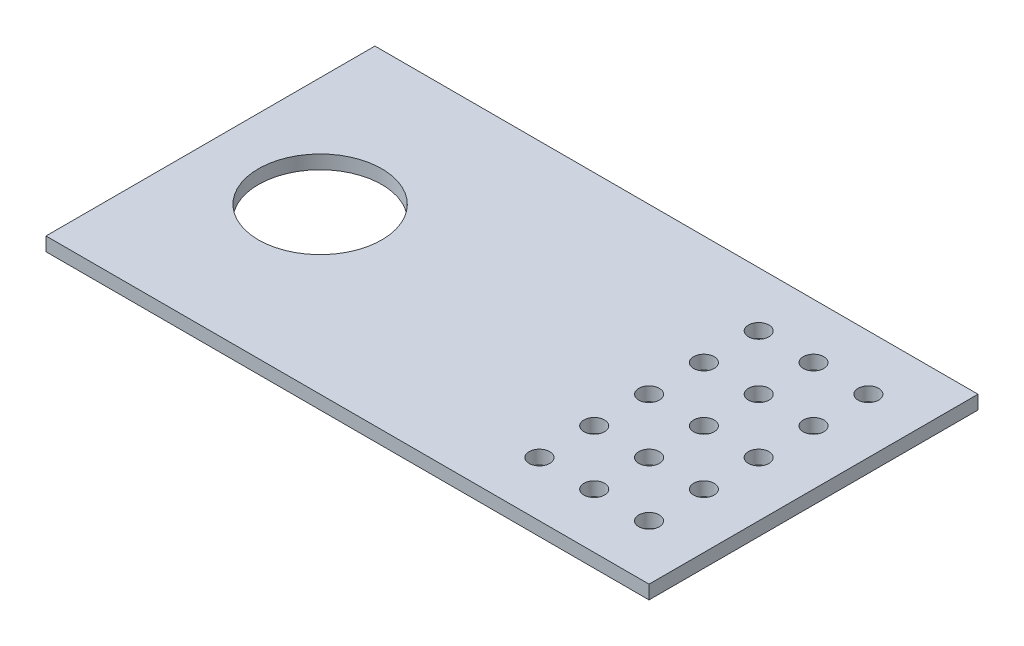
from build123d import *

# Parameters (mm, degrees)
SKETCH1_W           = 139.7
SKETCH1_H           = 76.2
SKETCH1_R           = 14.2875
SKETCH1_R_2         = 2.38125
BOSS_EXTRUDE1_DEPTH = 3.175


with BuildPart() as part:
    # Sketch1 → Boss-Extrude1 (new body)
    with BuildSketch(Plane(origin=(0, 0, 0), x_dir=(1, 0, 0), z_dir=(0, 1, 0))):
        with Locations((-69.85, 38.1)):
            Rectangle(SKETCH1_W, SKETCH1_H)
        with Locations((-114.3, 38.1)):
            Circle(SKETCH1_R, mode=Mode.SUBTRACT)
        with Locations((-38.1, 12.7)):
            Circle(SKETCH1_R_2, mode=Mode.SUBTRACT)
        with Locations((-25.4, 12.7)):
            Circle(SKETCH1_R_2, mode=Mode.SUBTRACT)
        with Locations((-12.7, 12.7)):
            Circle(SKETCH1_R_2, mode=Mode.SUBTRACT)
        with Locations((-25.4, 25.4)):
            Circle(SKETCH1_R_2, mode=Mode.SUBTRACT)
        with Locations((-12.7, 25.4)):
            Circle(SKETCH1_R_2, mode=Mode.SUBTRACT)
        with Locations((-25.4, 38.1)):
            Circle(SKETCH1_R_2, mode=Mode.SUBTRACT)
        with Locations((-12.7, 38.1)):
            Circle(SKETCH1_R_2, mode=Mode.SUBTRACT)
        with Locations((-25.4, 50.8)):
            Circle(SKETCH1_R_2, mode=Mode.SUBTRACT)
        with Locations((-12.7, 50.8)):
            Circle(SKETCH1_R_2, mode=Mode.SUBTRACT)
        with Locations((-25.4, 63.5)):
            Circle(SKETCH1_R_2, mode=Mode.SUBTRACT)
        with Locations((-12.7, 63.5)):
            Circle(SKETCH1_R_2, mode=Mode.SUBTRACT)
        with Locations((-38.1, 25.4)):
            Circle(SKETCH1_R_2, mode=Mode.SUBTRACT)
        with Locations((-38.1, 38.1)):
            Circle(SKETCH1_R_2, mode=Mode.SUBTRACT)
        with Locations((-38.1, 50.8)):
            Circle(SKETCH1_R_2, mode=Mode.SUBTRACT)
        with Locations((-38.1, 63.5)):
            Circle(SKETCH1_R_2, mode=Mode.SUBTRACT)
    extrude(amount=BOSS_EXTRUDE1_DEPTH)


solid = part.part
